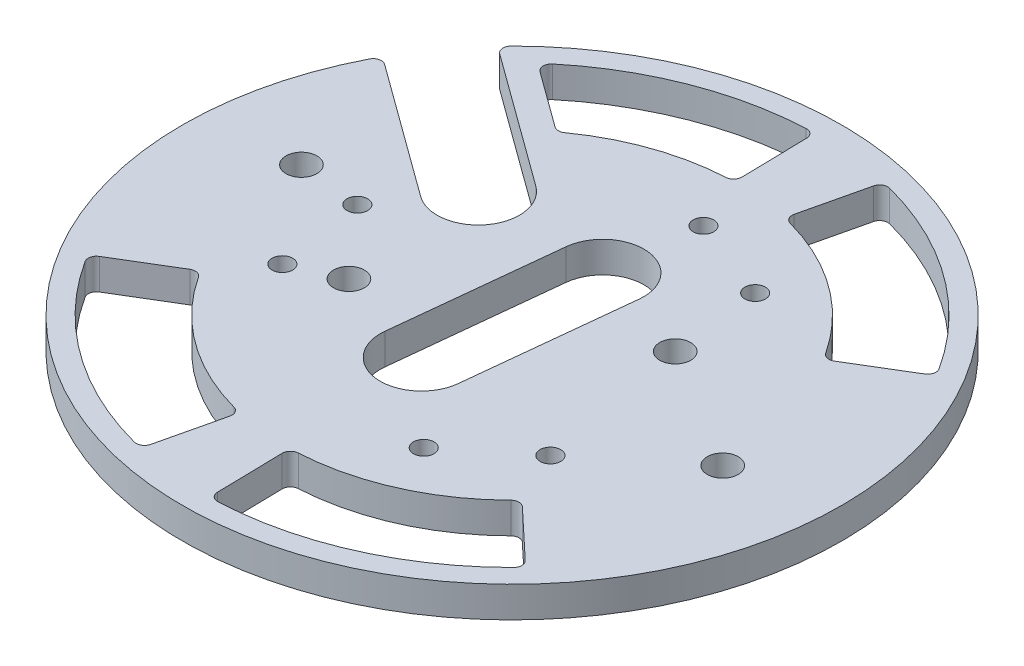
from build123d import *

# Parameters (mm, degrees)
SKETCH1_R           = 101.6
BOSS_EXTRUDE1_DEPTH = 9.525
SKETCH2_R           = 4.7625
SKETCH2_R_2         = 3.175
CUT_EXTRUDE1_DEPTH  = 22.86
SKETCH3_R           = 4.7625
CUT_EXTRUDE2_DEPTH  = 10.525
FILLET1_R           = 2.54
FILLET3_R           = 2.54


with BuildPart() as part:
    # Sketch1 → Boss-Extrude1 (new body)
    with BuildSketch(Plane(origin=(0, 0, 0), x_dir=(1, 0, 0), z_dir=(0, 1, 0))):
        Circle(SKETCH1_R)
    extrude(amount=BOSS_EXTRUDE1_DEPTH)

    # Sketch2 → Cut-Extrude1 (cut)
    with BuildSketch(Plane(origin=(0, 9.525, 0), x_dir=(1, 0, 0), z_dir=(0, 1, 0))):
        with BuildLine():
            Line((-9.955759688, 26.595729902), (-15.303128109, -23.922045692))
            ThreePointArc((-15.303128109, -23.922045692), (-4.010526316, -37.888331696), (9.955759688, -26.595729902))
            Line((9.955759688, -26.595729902), (15.303128109, 23.922045692))
            ThreePointArc((15.303128109, 23.922045692), (4.010526316, 37.888331696), (-9.955759688, 26.595729902))
        make_face()
        with Locations((34.817520913, 15.470948176)):
            Circle(SKETCH2_R)
        with Locations((-34.817520913, -15.470948176)):
            Circle(SKETCH2_R)
        with BuildLine():
            Line((-30.765292524, 38.093536125), (-87.237043764, 79.186441231))
            Line((-87.237043764, 79.186441231), (-104.485964967, 60.325))
            Line((-104.485964967, 60.325), (-45.710214871, 17.555539727))
            ThreePointArc((-45.710214871, 17.555539727), (-27.968755498, 20.352076753), (-30.765292524, 38.093536125))
        make_face()
        with Locations((5.646300897, 53.341856998)):
            Circle(SKETCH2_R_2)
        with Locations((31.560768513, 43.372252797)):
            Circle(SKETCH2_R_2)
        with Locations((-53.341856998, 5.646300897)):
            Circle(SKETCH2_R_2)
        with Locations((43.372252797, -31.560768513)):
            Circle(SKETCH2_R_2)
        with Locations((-49.018553694, -21.781088485)):
            Circle(SKETCH2_R_2)
        with Locations((21.781088485, -49.018553694)):
            Circle(SKETCH2_R_2)
    extrude(amount=-CUT_EXTRUDE1_DEPTH, mode=Mode.SUBTRACT)

    # Sketch3 → Cut-Extrude2 (cut, through all)
    with BuildSketch(Plane(origin=(0, 9.525, 0), x_dir=(1, 0, 0), z_dir=(0, 1, 0))):
        with BuildLine():
            ThreePointArc((15.979287148, 67.997682918), (41.099184753, 56.47901834), (59.78603337, 36.119976659))
            Line((59.78603337, 36.119976659), (81.526409141, 49.254513627))
            ThreePointArc((81.526409141, 49.254513627), (56.044342845, 77.016843191), (21.78993702, 92.72411307))
            Line((21.78993702, 92.72411307), (15.979287148, 67.997682918))
        make_face()
        with BuildLine():
            ThreePointArc((50.898077232, -47.837310063), (28.362672287, -63.832447241), (1.387800686, -69.83621202))
            Line((1.387800686, -69.83621202), (1.892455481, -95.231198209))
            ThreePointArc((1.892455481, -95.231198209), (38.6763713, -87.044246238), (69.406468953, -65.232695541))
            Line((69.406468953, -65.232695541), (50.898077232, -47.837310063))
        make_face()
        with BuildLine():
            ThreePointArc((-15.979287148, -67.997682918), (-41.099184753, -56.47901834), (-59.78603337, -36.119976659))
            Line((-59.78603337, -36.119976659), (-81.526409141, -49.254513627))
            ThreePointArc((-81.526409141, -49.254513627), (-56.044342845, -77.016843191), (-21.78993702, -92.72411307))
            Line((-21.78993702, -92.72411307), (-15.979287148, -67.997682918))
        make_face()
        with BuildLine():
            ThreePointArc((-42.080853774, 55.751450615), (-22.846796408, 66.00792675), (-1.387800686, 69.83621202))
            Line((-1.387800686, 69.83621202), (-1.892455481, 95.231198209))
            ThreePointArc((-1.892455481, 95.231198209), (-34.737758173, 88.689631058), (-63.288565419, 71.183705911))
            Line((-63.288565419, 71.183705911), (-42.080853774, 55.751450615))
        make_face()
        with Locations((-72.619302416, 7.686842105)):
            Circle(SKETCH3_R)
        with Locations((72.619302416, -7.686842105)):
            Circle(SKETCH3_R)
    extrude(amount=-CUT_EXTRUDE2_DEPTH, mode=Mode.SUBTRACT)

    # Fillet1
    fillet1_edges = [part.edges().sort_by_distance(p)[0] for p in [
        (-74.035185173, 4.7625, -69.579820037),
        (-88.980107519, 4.7625, -49.041823639),
    ]]
    fillet(fillet1_edges, radius=FILLET1_R)

    # Fillet3
    fillet3_edges = [part.edges().sort_by_distance(p)[0] for p in [
        (-15.979287148, 4.7625, 67.997682918),
        (-21.78993702, 4.7625, 92.72411307),
        (-81.526409141, 4.7625, 49.254513627),
        (-59.78603337, 4.7625, 36.119976659),
        (50.898077232, 4.7625, 47.837310063),
        (69.406468953, 4.7625, 65.232695541),
        (1.892455481, 4.7625, 95.231198209),
        (1.387800686, 4.7625, 69.83621202),
        (15.979287148, 4.7625, -67.997682918),
        (21.78993702, 4.7625, -92.72411307),
        (81.526409141, 4.7625, -49.254513627),
        (59.78603337, 4.7625, -36.119976659),
        (-42.080853774, 4.7625, -55.751450615),
        (-63.288565419, 4.7625, -71.183705911),
        (-1.892455481, 4.7625, -95.231198209),
        (-1.387800686, 4.7625, -69.83621202),
    ]]
    fillet(fillet3_edges, radius=FILLET3_R)


solid = part.part
